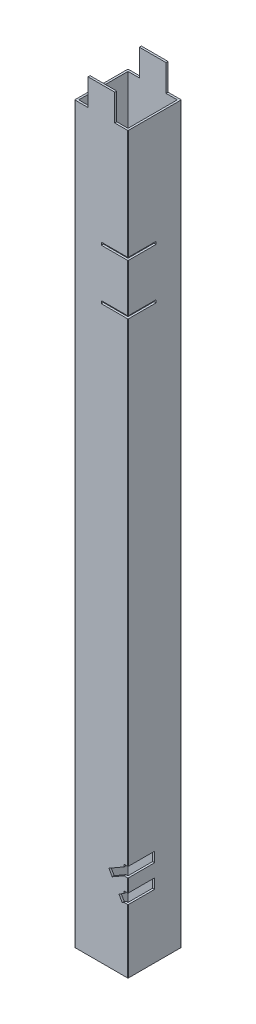
from build123d import *

# Parameters (mm, degrees)
SKETCH1_W           = 37
SKETCH1_H           = 37
BOSS_EXTRUDE1_DEPTH = 571
SKETCH2_W           = 10
SKETCH2_H           = 20
CUT_EXTRUDE1_DEPTH  = 40
SKETCH3_W           = 21
SKETCH3_H           = 2
CUT_EXTRUDE2_DEPTH  = 20
CUT_EXTRUDE3_START  = -40
CUT_EXTRUDE3_DEPTH  = 20
SKETCH5_R           = 3.5
CUT_EXTRUDE4_DEPTH  = 10


with BuildPart() as part:
    # Sketch1 → Boss-Extrude1 (new body)
    with BuildSketch(Plane(origin=(0, 0, 0), x_dir=(1, 0, 0), z_dir=(0, 1, 0))):
        with BuildLine():
            Line((0.5, 0), (39.5, 0))
            ThreePointArc((39.5, 0), (39.853553391, 0.146446609), (40, 0.5))
            Line((40, 0.5), (40, 39.5))
            ThreePointArc((40, 39.5), (39.853553391, 39.853553391), (39.5, 40))
            Line((39.5, 40), (0.5, 40))
            ThreePointArc((0.5, 40), (0.146446609, 39.853553391), (0, 39.5))
            Line((0, 39.5), (0, 0.5))
            ThreePointArc((0, 0.5), (0.146446609, 0.146446609), (0.5, 0))
        make_face()
        with Locations((20, 20)):
            Rectangle(SKETCH1_W, SKETCH1_H, mode=Mode.SUBTRACT)
    extrude(amount=BOSS_EXTRUDE1_DEPTH)

    # Sketch2 → Cut-Extrude1 (cut)
    with BuildSketch(Plane.XY.offset(-40)):
        with Locations((35, 561)):
            Rectangle(SKETCH2_W, SKETCH2_H)
        with Locations((5, 561)):
            Rectangle(SKETCH2_W, SKETCH2_H)
    extrude(amount=CUT_EXTRUDE1_DEPTH, mode=Mode.SUBTRACT)

    # Sketch3 → Cut-Extrude2 (cut)
    with BuildSketch(Plane(origin=(40, 0, 0), x_dir=(0, 0, -1), z_dir=(1, 0, 0))):
        with Locations((10.5, 467.5)):
            Rectangle(SKETCH3_W, SKETCH3_H)
        with Locations((10.5, 429.5)):
            Rectangle(SKETCH3_W, SKETCH3_H)
    extrude(amount=-CUT_EXTRUDE2_DEPTH, mode=Mode.SUBTRACT)

    # Sketch4 → Cut-Extrude3 (cut)
    with BuildSketch(Plane(origin=(0, 0, -40), x_dir=(-1, 0, 0), z_dir=(0, 0, -1)).offset(CUT_EXTRUDE3_START)):
        Polygon((-40, 72.59987752), (-37, 72.59987752), (-37, 70.867826713), (-25.659711467, 64.320508076), (-28.159711467, 59.990381057), (-37, 65.094324021), (-40, 65.094324021), align=None)
        Polygon((-40, 55.279369445), (-37, 55.279369445), (-37, 53.547318637), (-33.159711467, 51.330127019), (-35.659711467, 47), (-37, 47.773815945), (-40, 47.773815945), align=None)
    extrude(amount=CUT_EXTRUDE3_DEPTH, mode=Mode.SUBTRACT)

    # Sketch5 → Cut-Extrude4 (cut)
    with BuildSketch(Plane(origin=(0, 0, -40), x_dir=(-1, 0, 0), z_dir=(0, 0, -1))):
        with Locations((-30, 15)):
            Circle(SKETCH5_R)
        with Locations((-30, 30)):
            Circle(SKETCH5_R)
    extrude(amount=-CUT_EXTRUDE4_DEPTH, mode=Mode.SUBTRACT)


solid = part.part
